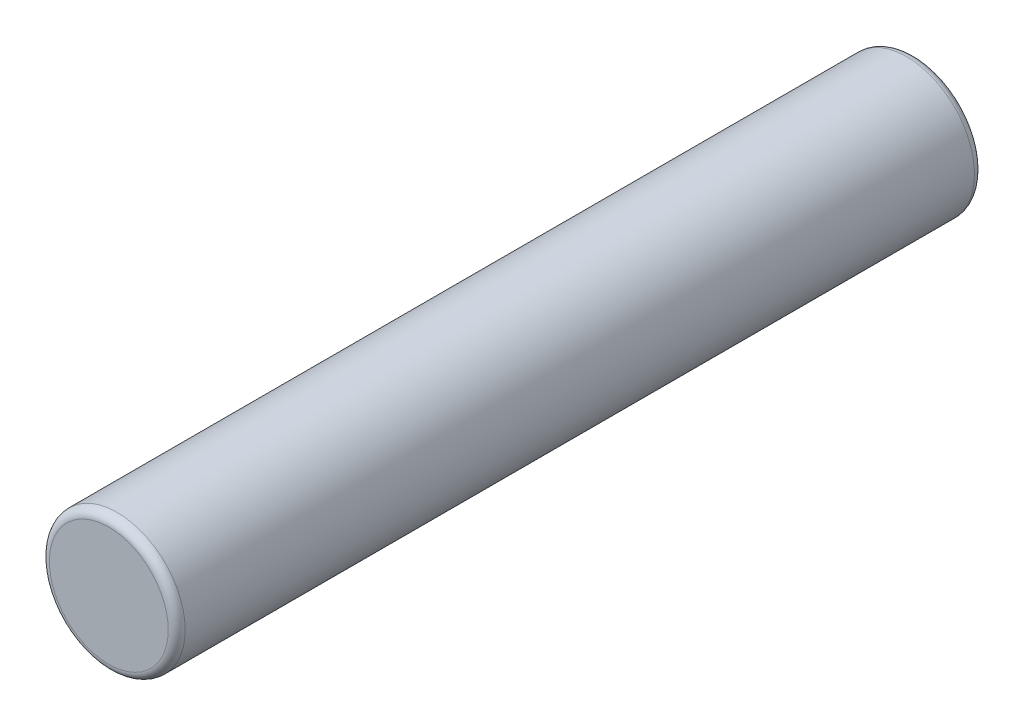
from build123d import *

# Parameters (mm, degrees)
SKETCH2_R           = 0.8
BOSS_EXTRUDE1_DEPTH = 9.5
FILLET1_R           = 0.1


with BuildPart() as part:
    # Sketch2 → Boss-Extrude1 (new body)
    with BuildSketch(Plane.XY):
        Circle(SKETCH2_R)
    extrude(amount=BOSS_EXTRUDE1_DEPTH)

    # Fillet1
    fillet1_edges = [part.edges().sort_by_distance(p)[0] for p in [
        (-0.8, 0, 0),
        (-0.8, 0, 9.5),
    ]]
    fillet(fillet1_edges, radius=FILLET1_R)


solid = part.part
